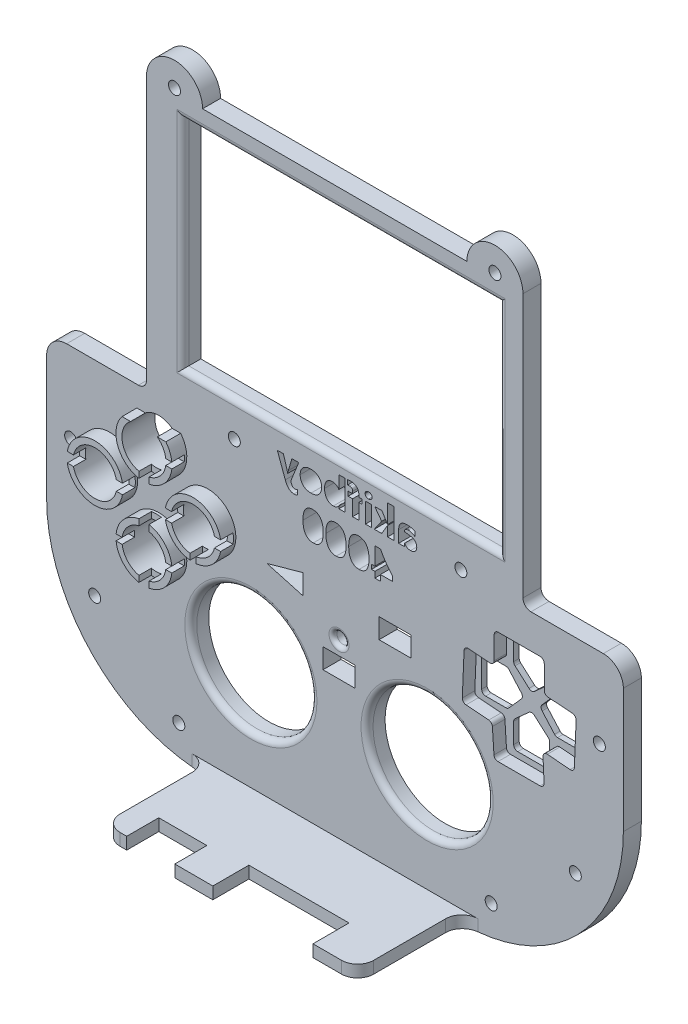
from build123d import *

# Parameters (mm, degrees)
SKETCH3_W           = 94
SKETCH3_H           = 68
SKETCH3_W_2         = 86.14
SKETCH3_H_2         = 60
SKETCH3_W_3         = 136
BOSS_EXTRUDE1_DEPTH = 4.5
FILLET1_R           = 40
FILLET3_R           = 2
FILLET4_R           = 5
SKETCH7_R           = 1.5
CUT_EXTRUDE1_DEPTH  = 5.5
SKETCH8_W           = 64
SKETCH8_H           = 3
BOSS_EXTRUDE2_DEPTH = 26
SKETCH10_W          = 12
SKETCH10_H          = 8
SKETCH10_W_2        = 25
SKETCH10_H_2        = 9
CUT_EXTRUDE2_DEPTH  = 4
SKETCH12_W          = 79
SKETCH12_H          = 54
CUT_EXTRUDE3_DEPTH  = 4.5
SKETCH13_R          = 15
CUT_EXTRUDE4_DEPTH  = 4.5
CUT_EXTRUDE5_DEPTH  = 4.5
FILLET7_R           = 1
FILLET8_R           = 1
CUT_EXTRUDE7_DEPTH  = 3.12
FILLET9_R           = 1
SKETCH16_R          = 5.5
CUT_EXTRUDE8_DEPTH  = 8.2
SKETCH17_R          = 7
SKETCH17_R_2        = 5.1
BOSS_EXTRUDE3_DEPTH = 3.7
SKETCH18_W          = 2.550563933
SKETCH18_H          = 2.5
SKETCH18_W_2        = 2.5
SKETCH18_H_2        = 2.523110448
SKETCH18_W_3        = 2.961814118
SKETCH18_H_3        = 1.5
SKETCH18_W_4        = 2.323205003
SKETCH18_W_5        = 2.376120163
SKETCH18_W_6        = 1.5
SKETCH18_H_4        = 2.429473953
SKETCH18_H_5        = 2.401401609
SKETCH18_W_7        = 2.803388964
CUT_EXTRUDE9_DEPTH  = 3.1
SKETCH19_R          = 1.5
SKETCH19_W          = 8
SKETCH19_H          = 5
CUT_EXTRUDE10_DEPTH = 4.5
SKETCH20_W          = 94
SKETCH20_H          = 4.5
CUT_EXTRUDE11_DEPTH = 0.23
SKETCH21_R          = 1.5
CUT_EXTRUDE12_DEPTH = 4.5
BOSS_EXTRUDE4_DEPTH = 4.5
SKETCH23_R          = 1.5
CUT_EXTRUDE13_DEPTH = 4.5
SKETCH24_R          = 1.5
CUT_EXTRUDE14_DEPTH = 4.5
SKETCH25_W          = 1.565789474
SKETCH25_H          = 4.973684211
CUT_EXTRUDE20_DEPTH = 4.5
SKETCH26_R          = 5.5
CUT_EXTRUDE21_DEPTH = 10
SKETCH27_W          = 13.162123603
SKETCH27_H          = 3.616908762
CUT_EXTRUDE22_DEPTH = 3.7
FILLET12_R          = 1.5
FILLET13_R          = 1
SKETCH28_W          = 29.55622263
SKETCH28_H          = 6.158319408
CUT_EXTRUDE23_DEPTH = 0.35
SKETCH29_W          = 27.097047007
SKETCH29_H          = 4.990966613
CUT_EXTRUDE24_DEPTH = 0.35
FILLET14_R          = 4


with BuildPart() as part:
    # Sketch3 → Boss-Extrude1 (new body)
    with BuildSketch(Plane.XY):
        Rectangle(SKETCH3_W, SKETCH3_H)
        Rectangle(SKETCH3_W_2, SKETCH3_H_2, mode=Mode.SUBTRACT)
        Polygon((47, -34), (-47, -34), (-71.93, -34), (-71.93, -110), (72.07, -110), (72.07, -34), align=None)
        with Locations((0.07, -72)):
            Rectangle(SKETCH3_W_3, SKETCH3_H, mode=Mode.SUBTRACT)
        Rectangle(SKETCH3_W_2, SKETCH3_H_2)
        with Locations((0.07, -72)):
            Rectangle(SKETCH3_W_3, SKETCH3_H)
    extrude(amount=BOSS_EXTRUDE1_DEPTH)

    # Fillet1
    fillet1_edges = [part.edges().sort_by_distance(p)[0] for p in [
        (72.07, -110, 2.25),
        (-71.93, -110, 2.25),
    ]]
    fillet(fillet1_edges, radius=FILLET1_R)

    # Fillet3
    fillet3_edges = [part.edges().sort_by_distance(p)[0] for p in [
        (47, -34, 2.25),
        (-47, -34, 2.25),
    ]]
    fillet(fillet3_edges, radius=FILLET3_R)

    # Fillet4
    fillet4_edges = [part.edges().sort_by_distance(p)[0] for p in [
        (72.07, -34, 2.25),
        (-71.93, -34, 2.25),
    ]]
    fillet(fillet4_edges, radius=FILLET4_R)

    # Sketch7 → Cut-Extrude1 (cut, through all)
    with BuildSketch(Plane.XY.offset(4.5)):
        with Locations((-25.07, -33.7)):
            Circle(SKETCH7_R)
        with Locations((31.5, -33.7)):
            Circle(SKETCH7_R)
    extrude(amount=-CUT_EXTRUDE1_DEPTH, mode=Mode.SUBTRACT)

    # Sketch8 → Boss-Extrude2 (add)
    with BuildSketch(Plane.XY.offset(4.5)):
        with Locations((0.07, -108.5)):
            Rectangle(SKETCH8_W, SKETCH8_H)
    extrude(amount=BOSS_EXTRUDE2_DEPTH)

    # Sketch10 → Cut-Extrude2 (cut)
    with BuildSketch(Plane.XZ.offset(110)):
        with Locations((-19.93, 26.5)):
            Rectangle(SKETCH10_W, SKETCH10_H)
        with Locations((8.07, 26)):
            Rectangle(SKETCH10_W_2, SKETCH10_H_2)
    extrude(amount=-CUT_EXTRUDE2_DEPTH, mode=Mode.SUBTRACT)

    # Sketch12 → Cut-Extrude3 (cut)
    with BuildSketch(Plane(origin=(0, 0, 0), x_dir=(-1, 0, 0), z_dir=(0, 0, -1))):
        with Locations((-1.57, 1.97)):
            Rectangle(SKETCH12_W, SKETCH12_H)
    extrude(amount=-CUT_EXTRUDE3_DEPTH, mode=Mode.SUBTRACT)

    # Sketch13 → Cut-Extrude4 (cut)
    with BuildSketch(Plane(origin=(0, 0, 0), x_dir=(-1, 0, 0), z_dir=(0, 0, -1))):
        with Locations((-23.07, -80)):
            Circle(SKETCH13_R)
        with Locations((20.93, -80)):
            Circle(SKETCH13_R)
    extrude(amount=-CUT_EXTRUDE4_DEPTH, mode=Mode.SUBTRACT)

    # Sketch14 → Cut-Extrude5 (cut)
    with BuildSketch(Plane(origin=(0, 0, 0), x_dir=(-1, 0, 0), z_dir=(0, 0, -1))):
        Polygon((-50.57, -50.5), (-46.07, -54.5), (-41.57, -50.5), (-41.57, -44), (-50.57, -44), align=None)
        Polygon((-50.57, -69), (-50.57, -62.5), (-46.07, -58.5), (-41.57, -62.5), (-41.57, -69), align=None)
        Polygon((-33.57, -52), (-33.57, -61), (-40.07, -61), (-44.07, -56.5), (-40.07, -52), align=None)
        Polygon((-58.57, -52), (-52.07, -52), (-48.07, -56.5), (-52.07, -61), (-58.57, -61), align=None)
    extrude(amount=-CUT_EXTRUDE5_DEPTH, mode=Mode.SUBTRACT)

    # Fillet7
    fillet7_edges = [part.edges().sort_by_distance(p)[0] for p in [
        (58.57, -61, 2.25),
        (58.57, -52, 2.25),
        (52.07, -52, 2.25),
        (48.07, -56.5, 2.25),
        (52.07, -61, 2.25),
        (50.57, -50.5, 2.25),
        (50.57, -44, 2.25),
        (41.57, -44, 2.25),
        (41.57, -50.5, 2.25),
        (46.07, -54.5, 2.25),
    ]]
    fillet(fillet7_edges, radius=FILLET7_R)

    # Fillet8
    fillet8_edges = [part.edges().sort_by_distance(p)[0] for p in [
        (40.07, -52, 2.25),
        (33.57, -52, 2.25),
        (33.57, -61, 2.25),
        (40.07, -61, 2.25),
        (44.07, -56.5, 2.25),
        (41.57, -69, 2.25),
        (50.57, -69, 2.25),
        (50.57, -62.5, 2.25),
        (46.07, -58.5, 2.25),
        (41.57, -62.5, 2.25),
    ]]
    fillet(fillet8_edges, radius=FILLET8_R)

    # Sketch15 → Cut-Extrude7 (cut)
    with BuildSketch(Plane.XY.offset(4.5)):
        Polygon((39.82, -42.5), (52.32, -42.5), (52.32, -50.25), (60.319152007, -50.841010066), (59.796347383, -63.330072293), (51.96198572, -62.643790261), (52.32, -70.5), (39.82, -70.5), (39.32, -62.75), (31.820847993, -62.158989934), (32.343652617, -49.669927707), (39.82, -50.25), align=None)
    extrude(amount=-CUT_EXTRUDE7_DEPTH, mode=Mode.SUBTRACT)

    # Fillet9
    fillet9_edges = [part.edges().sort_by_distance(p)[0] for p in [
        (39.82, -50.25, 2.94),
        (39.82, -42.5, 2.94),
        (52.32, -42.5, 2.94),
        (52.32, -50.25, 2.94),
        (60.319152007, -50.841010066, 2.94),
        (59.796347383, -63.330072293, 2.94),
        (51.96198572, -62.643790261, 2.94),
        (52.32, -70.5, 2.94),
        (39.82, -70.5, 2.94),
        (39.32, -62.75, 2.94),
        (31.820847993, -62.158989934, 2.94),
        (32.343652617, -49.669927707, 2.94),
    ]]
    fillet(fillet9_edges, radius=FILLET9_R)

    # Sketch16 → Cut-Extrude8 (cut)
    with BuildSketch(Plane(origin=(0, 0, 0), x_dir=(-1, 0, 0), z_dir=(0, 0, -1))):
        with Locations((43.93, -43.5)):
            Circle(SKETCH16_R)
        with Locations((31.68, -54.75)):
            Circle(SKETCH16_R)
        with Locations((56.18, -54.75)):
            Circle(SKETCH16_R)
        with Locations((43.93, -66)):
            Circle(SKETCH16_R)
    extrude(amount=-CUT_EXTRUDE8_DEPTH, mode=Mode.SUBTRACT)

    # Sketch17 → Boss-Extrude3 (add)
    with BuildSketch(Plane.XY.offset(4.5)):
        with Locations((-43.93, -43.5)):
            Circle(SKETCH17_R)
        with Locations((-43.93, -43.5)):
            Circle(SKETCH17_R_2, mode=Mode.SUBTRACT)
        with Locations((-31.68, -54.75)):
            Circle(SKETCH17_R)
        with Locations((-31.68, -54.75)):
            Circle(SKETCH17_R_2, mode=Mode.SUBTRACT)
        with Locations((-43.93, -66)):
            Circle(SKETCH17_R)
        with Locations((-43.93, -66)):
            Circle(SKETCH17_R_2, mode=Mode.SUBTRACT)
        with Locations((-56.18, -54.75)):
            Circle(SKETCH17_R)
        with Locations((-56.18, -54.75)):
            Circle(SKETCH17_R_2, mode=Mode.SUBTRACT)
    extrude(amount=BOSS_EXTRUDE3_DEPTH)

    # Sketch18 → Cut-Extrude9 (cut)
    with BuildSketch(Plane.XY.offset(8.2)):
        with Locations((-62.358387201, -54.75)):
            Rectangle(SKETCH18_W, SKETCH18_H)
        with Locations((-50.0016128, -54.75)):
            Rectangle(SKETCH18_W, SKETCH18_H)
        with Locations((-43.93, -49.575016155)):
            Rectangle(SKETCH18_W_2, SKETCH18_H_2)
        with Locations((-43.93, -37.424983845)):
            Rectangle(SKETCH18_W_2, SKETCH18_H_2)
        with Locations((-37.86326354, -43.5)):
            Rectangle(SKETCH18_W_3, SKETCH18_H_3)
        with Locations((-37.676163082, -54.75)):
            Rectangle(SKETCH18_W_4, SKETCH18_H)
        with Locations((-25.845860503, -54.75)):
            Rectangle(SKETCH18_W_5, SKETCH18_H)
        with Locations((-31.68, -60.701386037)):
            Rectangle(SKETCH18_W_6, SKETCH18_H_4)
        with Locations((-43.93, -60.086956195)):
            Rectangle(SKETCH18_W_2, SKETCH18_H_5)
        with Locations((-43.93, -71.913043805)):
            Rectangle(SKETCH18_W_2, SKETCH18_H_5)
        with Locations((-38.240309623, -66)):
            Rectangle(SKETCH18_W_7, SKETCH18_H_3)
        with Locations((-49.619690377, -66)):
            Rectangle(SKETCH18_W_7, SKETCH18_H_3)
    extrude(amount=-CUT_EXTRUDE9_DEPTH, mode=Mode.SUBTRACT)

    # Sketch19 → Cut-Extrude10 (cut)
    with BuildSketch(Plane(origin=(0, 0, 0), x_dir=(-1, 0, 0), z_dir=(0, 0, -1))):
        with Locations((-1.07, -64)):
            Circle(SKETCH19_R)
        Polygon((7.93, -54), (7.93, -59), (16.93, -56.5), align=None)
        with Locations((-15.07, -56.5)):
            Rectangle(SKETCH19_W, SKETCH19_H)
        with Locations((-1.07, -70)):
            Rectangle(SKETCH19_W, SKETCH19_H)
    extrude(amount=-CUT_EXTRUDE10_DEPTH, mode=Mode.SUBTRACT)

    # Sketch20 → Cut-Extrude11 (cut)
    with BuildSketch(Plane(origin=(0, 34, 0), x_dir=(1, 0, 0), z_dir=(0, 1, 0))):
        with Locations((0, -2.25)):
            Rectangle(SKETCH20_W, SKETCH20_H)
    extrude(amount=-CUT_EXTRUDE11_DEPTH, mode=Mode.SUBTRACT)

    # Sketch21 → Cut-Extrude12 (cut)
    with BuildSketch(Plane(origin=(0, 0, 0), x_dir=(-1, 0, 0), z_dir=(0, 0, -1))):
        with Locations((-39.07, -102)):
            Circle(SKETCH21_R)
        with Locations((38.93, -102)):
            Circle(SKETCH21_R)
    extrude(amount=-CUT_EXTRUDE12_DEPTH, mode=Mode.SUBTRACT)

    # Sketch22 → Boss-Extrude4 (add)
    with BuildSketch(Plane(origin=(0, 0, 0), x_dir=(-1, 0, 0), z_dir=(0, 0, -1))):
        with BuildLine():
            Line((-47, 33.77), (-33, 33.77))
            ThreePointArc((-33, 33.77), (-40, 40.77), (-47, 33.77))
        make_face()
        with BuildLine():
            Line((47, 33.77), (33, 33.77))
            ThreePointArc((33, 33.77), (40, 40.77), (47, 33.77))
        make_face()
    extrude(amount=-BOSS_EXTRUDE4_DEPTH)

    # Sketch23 → Cut-Extrude13 (cut)
    with BuildSketch(Plane(origin=(0, 0, 0), x_dir=(-1, 0, 0), z_dir=(0, 0, -1))):
        with Locations((-40, 34.77)):
            Circle(SKETCH23_R)
        with Locations((40, 34.77)):
            Circle(SKETCH23_R)
    extrude(amount=-CUT_EXTRUDE13_DEPTH, mode=Mode.SUBTRACT)

    # Sketch24 → Cut-Extrude14 (cut)
    with BuildSketch(Plane(origin=(0, 0, 0), x_dir=(-1, 0, 0), z_dir=(0, 0, -1))):
        with Locations((65.93, -54)):
            Circle(SKETCH24_R)
        with Locations((59.93, -85)):
            Circle(SKETCH24_R)
        with Locations((-66.07, -54)):
            Circle(SKETCH24_R)
        with Locations((-60.07, -85)):
            Circle(SKETCH24_R)
    extrude(amount=-CUT_EXTRUDE14_DEPTH, mode=Mode.SUBTRACT)

    # Sketch25 → Cut-Extrude20 (cut)
    with BuildSketch(Plane(origin=(0, 0, 0), x_dir=(-1, 0, 0), z_dir=(0, 0, -1))):
        with BuildLine():
            Line((14.331052632, -30.726315789), (12.339276316, -36.141817434))
            add(Edge.make_bspline(
                [(12.339276316, -36.141817434), (12.309435587, -36.220844542), (12.25099053, -36.375624399), (12.15089745, -36.596311688), (12.047921736, -36.803734021), (11.936884142, -36.994401064), (11.822187613, -37.171037104), (11.700673172, -37.331398984), (11.57431277, -37.477166889), (11.44167923, -37.607999313), (11.301372746, -37.721126414), (11.15745927, -37.821823684), (11.006627122, -37.905247886), (10.850969781, -37.97521784), (10.689104709, -38.027906022), (10.522248726, -38.067554511), (10.349131502, -38.090985435), (10.231479495, -38.093476083), (10.171924342, -38.094736842)],
                knots=[0, 0, 0, 0, 0.000253355, 0.000496212, 0.000726624, 0.000947794, 0.001157751, 0.001358082, 0.001550868, 0.001736088, 0.001916125, 0.002090974, 0.002262347, 0.002432434, 0.002602186, 0.002772188, 0.002946413, 0.003125012, 0.003125012, 0.003125012, 0.003125012], degree=3))
            add(Edge.make_bspline(
                [(10.171924342, -38.094736842), (10.0839903, -38.092780835), (9.915538502, -38.089033788), (9.675343221, -38.053815015), (9.457872968, -37.999033788), (9.327881454, -37.939300484), (9.265263158, -37.910526316)],
                knots=[0, 0, 0, 0, 0.000263615, 0.000504997, 0.000727022, 0.000933378, 0.000933378, 0.000933378, 0.000933378], degree=3))
            Line((9.265263158, -37.910526316), (9.265263158, -36.713157895))
            add(Edge.make_bspline(
                [(9.265263158, -36.713157895), (9.315373417, -36.741592816), (9.414801427, -36.798012951), (9.576382338, -36.854580595), (9.743814417, -36.891076839), (9.857996079, -36.895254891), (9.915756579, -36.897368421)],
                knots=[0, 0, 0, 0, 0.000172529, 0.00034233, 0.000511398, 0.000684478, 0.000684478, 0.000684478, 0.000684478], degree=3))
            add(Edge.make_bspline(
                [(9.915756579, -36.897368421), (9.962407983, -36.895802705), (10.052646598, -36.892774113), (10.182564561, -36.866817624), (10.301031255, -36.821539426), (10.408257758, -36.758569261), (10.5067581, -36.680804272), (10.590591291, -36.581493919), (10.66415487, -36.465986333), (10.703052198, -36.380301273), (10.723116776, -36.336101974)],
                knots=[0, 0, 0, 0, 0.000139864, 0.000270541, 0.000395357, 0.000518528, 0.00064237, 0.000769903, 0.00090644, 0.001051907, 0.001051907, 0.001051907, 0.001051907], degree=3))
            Line((10.723116776, -36.336101974), (10.979284539, -35.715830592))
            Line((10.979284539, -35.715830592), (8.988947368, -30.726315789))
            Line((8.988947368, -30.726315789), (10.688577303, -30.726315789))
            Line((10.688577303, -30.726315789), (11.589481908, -33.772985197))
            add(Edge.make_bspline(
                [(11.589481908, -33.772985197), (11.603370114, -33.822277684), (11.632189823, -33.924565559), (11.667828036, -34.085940109), (11.69776615, -34.260365129), (11.713668278, -34.381202677), (11.721883224, -34.443626645)],
                knots=[0, 0, 0, 0, 0.000153611, 0.000318762, 0.000495502, 0.000684376, 0.000684376, 0.000684376, 0.000684376], degree=3))
            Line((11.721883224, -34.443626645), (11.740592105, -34.443626645))
            add(Edge.make_bspline(
                [(11.740592105, -34.443626645), (11.74880851, -34.394138093), (11.765872062, -34.291361938), (11.80107938, -34.131962601), (11.84617424, -33.961476505), (11.879965, -33.843919752), (11.897458882, -33.783059211)],
                knots=[0, 0, 0, 0, 0.000150478, 0.000312508, 0.000489482, 0.000679455, 0.000679455, 0.000679455, 0.000679455], degree=3))
            Line((11.897458882, -33.783059211), (12.809876645, -30.726315789))
            Line((12.809876645, -30.726315789), (14.331052632, -30.726315789))
        make_face()
        with BuildLine():
            add(Edge.make_bspline(
                [(5.925008224, -35.792105263), (5.82463653, -35.790573816), (5.629066873, -35.787589862), (5.344796963, -35.752788216), (5.076486328, -35.701148771), (4.825322649, -35.623898458), (4.589186289, -35.527694534), (4.368828149, -35.409711049), (4.166897637, -35.267539879), (3.982027012, -35.106019501), (3.816426271, -34.926075388), (3.67191748, -34.729783848), (3.549674956, -34.517403062), (3.451318538, -34.289609069), (3.372102271, -34.047067807), (3.318976159, -33.788760166), (3.284835927, -33.515330455), (3.280594694, -33.327916731), (3.278421053, -33.231866776)],
                knots=[0, 0, 0, 0, 0.00030095, 0.000586387, 0.000857902, 0.001119672, 0.001373296, 0.001621848, 0.001867786, 0.002112559, 0.002357002, 0.00259994, 0.00284235, 0.003090472, 0.003343061, 0.003606409, 0.003880414, 0.004168473, 0.004168473, 0.004168473, 0.004168473], degree=3))
            add(Edge.make_bspline(
                [(3.278421053, -33.231866776), (3.280535444, -33.132944833), (3.284664906, -32.939747691), (3.319610134, -32.658354216), (3.377192299, -32.393984975), (3.455660946, -32.145326326), (3.560603222, -31.914473314), (3.685355683, -31.697836538), (3.836543839, -31.500372902), (4.008136476, -31.319659663), (4.200049693, -31.159088566), (4.407539139, -31.016906055), (4.632764216, -30.898187395), (4.873986665, -30.802775564), (5.130202626, -30.724907008), (5.403855379, -30.673599012), (5.692887999, -30.638832469), (5.891319405, -30.635772893), (5.992648026, -30.634210526)],
                knots=[0, 0, 0, 0, 0.000296687, 0.000579438, 0.000849019, 0.001107529, 0.001360033, 0.001608342, 0.001855879, 0.002104256, 0.002354489, 0.002605165, 0.002857525, 0.003116483, 0.003382386, 0.003659547, 0.003950703, 0.00425453, 0.00425453, 0.00425453, 0.00425453], degree=3))
            add(Edge.make_bspline(
                [(5.992648026, -30.634210526), (6.092543008, -30.635730023), (6.287162068, -30.638690363), (6.570431535, -30.673704113), (6.837886429, -30.724924538), (7.088000332, -30.802504917), (7.322483782, -30.898225391), (7.54047563, -31.017069173), (7.740719771, -31.158772916), (7.924271956, -31.320260037), (8.087337991, -31.50003842), (8.231702988, -31.693426843), (8.350607496, -31.902625863), (8.451513235, -32.123559396), (8.527159583, -32.359975241), (8.58200341, -32.609484453), (8.613515903, -32.873195716), (8.618153114, -33.053330084), (8.620526316, -33.145518092)],
                knots=[0, 0, 0, 0, 0.000299512, 0.000583519, 0.000855034, 0.001115428, 0.001367722, 0.001613744, 0.001858504, 0.002102196, 0.002345667, 0.002585435, 0.002824632, 0.003066176, 0.003312846, 0.003567753, 0.003831584, 0.00410814, 0.00410814, 0.00410814, 0.00410814], degree=3))
            add(Edge.make_bspline(
                [(8.620526316, -33.145518092), (8.618292567, -33.244909846), (8.613930846, -33.438986728), (8.580607932, -33.722253114), (8.524791517, -33.989736049), (8.44613107, -34.241353546), (8.342494274, -34.476090314), (8.219390227, -34.696233489), (8.070917448, -34.898601558), (7.902455416, -35.084652276), (7.714257952, -35.251920581), (7.506853044, -35.39596555), (7.284410984, -35.519404622), (7.044052431, -35.618506347), (6.788148034, -35.698476879), (6.514422212, -35.751595958), (6.225214977, -35.78571813), (6.026809855, -35.789939354), (5.925008224, -35.792105263)],
                knots=[0, 0, 0, 0, 0.000298125, 0.000582133, 0.000854227, 0.00111685, 0.0013714, 0.001622735, 0.001872019, 0.002122654, 0.002374471, 0.002625597, 0.002878743, 0.003136129, 0.003404246, 0.003681688, 0.003971414, 0.00427673, 0.00427673, 0.00427673, 0.00427673], degree=3))
        make_face()
        with BuildLine():
            Line((-1.031817434, -35.069654605), (-1.050526316, -35.069654605))
            Line((-1.050526316, -35.069654605), (-1.050526316, -35.7))
            Line((-1.050526316, -35.7), (-2.616315789, -35.7))
            Line((-2.616315789, -35.7), (-2.616315789, -28.331578947))
            Line((-2.616315789, -28.331578947), (-1.050526316, -28.331578947))
            Line((-1.050526316, -28.331578947), (-1.050526316, -31.526480263))
            Line((-1.050526316, -31.526480263), (-1.031817434, -31.526480263))
            add(Edge.make_bspline(
                [(-1.031817434, -31.526480263), (-0.984047056, -31.455673996), (-0.890819126, -31.317489583), (-0.726260308, -31.135353995), (-0.548751979, -30.978736508), (-0.353978558, -30.853553028), (-0.145737277, -30.753082099), (0.07871865, -30.685545028), (0.317385729, -30.642089955), (0.481485287, -30.6368814), (0.565633224, -30.634210526)],
                knots=[0, 0, 0, 0, 0.000255966, 0.000499538, 0.000734159, 0.000964084, 0.001191965, 0.001425484, 0.001665165, 0.001917426, 0.001917426, 0.001917426, 0.001917426], degree=3))
            add(Edge.make_bspline(
                [(0.565633224, -30.634210526), (0.642476456, -30.636101007), (0.792468479, -30.639791079), (1.010795915, -30.669781204), (1.214887132, -30.722534622), (1.406661306, -30.791948296), (1.583387576, -30.885665345), (1.747769986, -30.997937017), (1.895997208, -31.133618487), (2.032031108, -31.286639873), (2.152523244, -31.457660552), (2.255862032, -31.645108124), (2.346257068, -31.845734746), (2.417540065, -32.063052753), (2.473101981, -32.29464371), (2.513789647, -32.540824763), (2.536133034, -32.802106322), (2.53973032, -32.981415009), (2.541578947, -33.073560855)],
                knots=[0, 0, 0, 0, 0.000230483, 0.000449886, 0.000659315, 0.000861948, 0.001060216, 0.00125782, 0.001457534, 0.001661426, 0.001871053, 0.002083662, 0.0023027, 0.002530249, 0.002768652, 0.003016603, 0.003278104, 0.003554555, 0.003554555, 0.003554555, 0.003554555], degree=3))
            add(Edge.make_bspline(
                [(2.541578947, -33.073560855), (2.539451692, -33.173395534), (2.535291301, -33.368647679), (2.508434326, -33.654552929), (2.460741034, -33.924758354), (2.396304198, -34.180715334), (2.311960751, -34.420866834), (2.20713095, -34.645235231), (2.086397716, -34.855880304), (1.945714949, -35.048630452), (1.790791338, -35.224053632), (1.620140983, -35.375463939), (1.437790187, -35.504457699), (1.243352727, -35.611537618), (1.034547918, -35.690935649), (0.814533175, -35.751059987), (0.581125601, -35.785735421), (0.421351954, -35.789950716), (0.3396875, -35.792105263)],
                knots=[0, 0, 0, 0, 0.000299512, 0.000585771, 0.000860467, 0.001121905, 0.0013768, 0.001622759, 0.001863922, 0.002104, 0.002337413, 0.002564729, 0.002786736, 0.003006341, 0.003228697, 0.003455265, 0.003689528, 0.003934453, 0.003934453, 0.003934453, 0.003934453], degree=3))
            add(Edge.make_bspline(
                [(0.3396875, -35.792105263), (0.266656057, -35.789841168), (0.124130559, -35.785422642), (-0.083563533, -35.752479588), (-0.277236408, -35.69448279), (-0.457379949, -35.615075116), (-0.623576742, -35.513103147), (-0.775570619, -35.388266199), (-0.914022837, -35.240080208), (-0.991949532, -35.127335615), (-1.031817434, -35.069654605)],
                knots=[0, 0, 0, 0, 0.000219053, 0.000427495, 0.000628749, 0.00082397, 0.001016493, 0.001211819, 0.001412419, 0.001622553, 0.001622553, 0.001622553, 0.001622553], degree=3))
        make_face()
        with BuildLine():
            add(Edge.make_bspline(
                [(-3.168947368, -29.528947368), (-3.216723741, -29.514742492), (-3.310967111, -29.486722042), (-3.453074273, -29.458750598), (-3.592523048, -29.440176214), (-3.684582905, -29.437947034), (-3.730213816, -29.436842105)],
                knots=[0, 0, 0, 0, 0.000149449, 0.000294803, 0.000434036, 0.000570876, 0.000570876, 0.000570876, 0.000570876], degree=3))
            add(Edge.make_bspline(
                [(-3.730213816, -29.436842105), (-3.787576416, -29.43839805), (-3.895564895, -29.441327208), (-4.045811982, -29.480214935), (-4.174893721, -29.540012116), (-4.280245395, -29.62818461), (-4.363111026, -29.740308287), (-4.417837897, -29.878144841), (-4.453231939, -30.038063651), (-4.456617453, -30.152836279), (-4.458421053, -30.213980263)],
                knots=[0, 0, 0, 0, 0.000171645, 0.000323131, 0.000462164, 0.000595018, 0.000730878, 0.00087601, 0.001036635, 0.001219768, 0.001219768, 0.001219768, 0.001219768], degree=3))
            Line((-4.458421053, -30.213980263), (-4.458421053, -30.726315789))
            Line((-4.458421053, -30.726315789), (-3.353157895, -30.726315789))
            Line((-3.353157895, -30.726315789), (-3.353157895, -31.831578947))
            Line((-3.353157895, -31.831578947), (-4.458421053, -31.831578947))
            Line((-4.458421053, -31.831578947), (-4.458421053, -35.7))
            Line((-4.458421053, -35.7), (-6.024210526, -35.7))
            Line((-6.024210526, -35.7), (-6.024210526, -31.831578947))
            Line((-6.024210526, -31.831578947), (-6.853157895, -31.831578947))
            Line((-6.853157895, -31.831578947), (-6.853157895, -30.726315789))
            Line((-6.853157895, -30.726315789), (-6.024210526, -30.726315789))
            Line((-6.024210526, -30.726315789), (-6.024210526, -30.114679276))
            add(Edge.make_bspline(
                [(-6.024210526, -30.114679276), (-6.022628178, -30.045993583), (-6.019529149, -29.911472696), (-5.993069916, -29.715321919), (-5.9502718, -29.528908808), (-5.887942871, -29.353670913), (-5.809892213, -29.187166763), (-5.713083373, -29.032218807), (-5.599946187, -28.88635789), (-5.46884875, -28.753505353), (-5.323784467, -28.632205669), (-5.164373145, -28.526833445), (-4.992828763, -28.437164954), (-4.808038394, -28.365636678), (-4.611931842, -28.307326522), (-4.402679482, -28.267672879), (-4.18117559, -28.244859426), (-4.029610108, -28.241300013), (-3.951842105, -28.239473684)],
                knots=[0, 0, 0, 0, 0.000205979, 0.000403409, 0.000592612, 0.000778774, 0.000960312, 0.001143219, 0.001325735, 0.00151299, 0.001702044, 0.001892039, 0.002085147, 0.002281573, 0.002485587, 0.002698118, 0.002919508, 0.003152809, 0.003152809, 0.003152809, 0.003152809], degree=3))
            add(Edge.make_bspline(
                [(-3.951842105, -28.239473684), (-3.876483139, -28.240447199), (-3.732266207, -28.242310245), (-3.52609977, -28.259880383), (-3.339468798, -28.2867945), (-3.223902519, -28.317145946), (-3.168947368, -28.331578947)],
                knots=[0, 0, 0, 0, 0.000226019, 0.00043254, 0.000620408, 0.000790744, 0.000790744, 0.000790744, 0.000790744], degree=3))
            Line((-3.168947368, -28.331578947), (-3.168947368, -29.528947368))
        make_face()
        with BuildLine():
            add(Edge.make_bspline(
                [(-8.465, -29.897368421), (-8.526206527, -29.894819394), (-8.644979388, -29.889872939), (-8.813885792, -29.845529357), (-8.966665194, -29.774049785), (-9.097627706, -29.673542334), (-9.20491091, -29.552755134), (-9.282973123, -29.416154608), (-9.331220259, -29.265865907), (-9.337032252, -29.160884217), (-9.34, -29.107277961)],
                knots=[0, 0, 0, 0, 0.000183337, 0.00035577, 0.000519921, 0.00068629, 0.000847397, 0.001001446, 0.001155294, 0.001315821, 0.001315821, 0.001315821, 0.001315821], degree=3))
            add(Edge.make_bspline(
                [(-9.34, -29.107277961), (-9.337158955, -29.052211587), (-9.331666079, -28.945746255), (-9.283126312, -28.794517668), (-9.205975579, -28.659307707), (-9.097196562, -28.543610176), (-8.965635171, -28.449171338), (-8.813492979, -28.380703439), (-8.644857488, -28.337606123), (-8.526193889, -28.333629606), (-8.465, -28.331578947)],
                knots=[0, 0, 0, 0, 0.000164824, 0.000318672, 0.000471472, 0.000628306, 0.000791254, 0.000954189, 0.001126267, 0.001309497, 0.001309497, 0.001309497, 0.001309497], degree=3))
            add(Edge.make_bspline(
                [(-8.465, -28.331578947), (-8.402818847, -28.333522316), (-8.283141762, -28.337262623), (-8.113415067, -28.381198656), (-7.960655845, -28.447877364), (-7.831132463, -28.544659397), (-7.722627768, -28.659221911), (-7.645055151, -28.794280376), (-7.598793144, -28.946026154), (-7.59300023, -29.052258683), (-7.59, -29.107277961)],
                knots=[0, 0, 0, 0, 0.000186101, 0.00035818, 0.000522425, 0.000683043, 0.000839877, 0.000992677, 0.001146099, 0.001310924, 0.001310924, 0.001310924, 0.001310924], degree=3))
            add(Edge.make_bspline(
                [(-7.59, -29.107277961), (-7.593046483, -29.162763357), (-7.598954775, -29.270370682), (-7.644997043, -29.424487544), (-7.722550459, -29.562312535), (-7.830552605, -29.679926971), (-7.960620944, -29.777960276), (-8.113048607, -29.846729086), (-8.283248501, -29.889793913), (-8.402844189, -29.894778073), (-8.465, -29.897368421)],
                knots=[0, 0, 0, 0, 0.000166257, 0.000322436, 0.000477737, 0.000636695, 0.000798169, 0.000963012, 0.00113509, 0.001321297, 0.001321297, 0.001321297, 0.001321297], degree=3))
        make_face()
        with Locations((-8.465, -33.213157895)):
            Rectangle(SKETCH25_W, SKETCH25_H)
        Polygon((-9.892631579, -35.7), (-11.733297697, -35.7), (-13.191151316, -33.231866776), (-13.208421053, -33.231866776), (-13.208421053, -35.7), (-14.774210526, -35.7), (-14.774210526, -28.331578947), (-13.208421053, -28.331578947), (-13.208421053, -33.023190789), (-13.189712171, -33.023190789), (-11.806694079, -30.726315789), (-9.984736842, -30.726315789), (-11.727541118, -33.062047697), align=None)
        with BuildLine():
            Line((-15.971578947, -35.7), (-17.445263158, -35.7))
            Line((-17.445263158, -35.7), (-17.445263158, -34.940131579))
            Line((-17.445263158, -34.940131579), (-17.463972039, -34.940131579))
            add(Edge.make_bspline(
                [(-17.463972039, -34.940131579), (-17.506429315, -35.008007619), (-17.589001681, -35.140015273), (-17.738071993, -35.313801217), (-17.899703585, -35.463091399), (-18.079134065, -35.583543004), (-18.272864426, -35.677764588), (-18.481805942, -35.743967207), (-18.705251629, -35.785632188), (-18.859751734, -35.789908936), (-18.939095395, -35.792105263)],
                knots=[0, 0, 0, 0, 0.000239889, 0.000466544, 0.000684554, 0.000898101, 0.001112437, 0.00132862, 0.001553882, 0.001791694, 0.001791694, 0.001791694, 0.001791694], degree=3))
            add(Edge.make_bspline(
                [(-18.939095395, -35.792105263), (-18.997692416, -35.791340265), (-19.111902248, -35.789849228), (-19.277824322, -35.768425257), (-19.434499016, -35.737428602), (-19.581736436, -35.69304674), (-19.718848203, -35.635004091), (-19.847465983, -35.565837949), (-19.964985041, -35.481773238), (-20.0738328, -35.387016728), (-20.169121519, -35.279921052), (-20.255896923, -35.166342281), (-20.326157735, -35.04137984), (-20.383216526, -34.908369599), (-20.430621053, -34.768204913), (-20.460914461, -34.618287912), (-20.482411936, -34.460561477), (-20.48395237, -34.352079044), (-20.484736842, -34.296833882)],
                knots=[0, 0, 0, 0, 0.00017567, 0.000342394, 0.000501013, 0.000654436, 0.000802779, 0.000947039, 0.001091585, 0.001235363, 0.001379025, 0.001520925, 0.001663371, 0.001807746, 0.001954743, 0.002106318, 0.002265901, 0.002431503, 0.002431503, 0.002431503, 0.002431503], degree=3))
            add(Edge.make_bspline(
                [(-20.484736842, -34.296833882), (-20.483319055, -34.238726624), (-20.480544995, -34.125033168), (-20.459906585, -33.958930819), (-20.427472437, -33.802233787), (-20.381301825, -33.654878662), (-20.320265388, -33.517701957), (-20.247010878, -33.389048316), (-20.160081438, -33.270296868), (-20.059624364, -33.161273823), (-19.945650305, -33.062012868), (-19.818231693, -32.972510466), (-19.677265898, -32.892994042), (-19.523249891, -32.823488892), (-19.357047866, -32.76023072), (-19.175942108, -32.711246302), (-18.982349197, -32.66927999), (-18.848085685, -32.649212546), (-18.779350329, -32.638939145)],
                knots=[0, 0, 0, 0, 0.000174285, 0.000341009, 0.00050133, 0.000653804, 0.000803288, 0.000950911, 0.001097139, 0.001243804, 0.001394757, 0.001549677, 0.001710153, 0.00187952, 0.002056213, 0.002243025, 0.002441742, 0.002650184, 0.002650184, 0.002650184, 0.002650184], degree=3))
            Line((-18.779350329, -32.638939145), (-17.435189145, -32.460485197))
            add(Edge.make_bspline(
                [(-17.435189145, -32.460485197), (-17.437735933, -32.396912726), (-17.442564438, -32.276384479), (-17.484206213, -32.107742162), (-17.554145252, -31.963711562), (-17.653081214, -31.844471716), (-17.782887905, -31.753443097), (-17.940080997, -31.691082534), (-18.123780011, -31.653832633), (-18.254829797, -31.649613852), (-18.324580592, -31.647368421)],
                knots=[0, 0, 0, 0, 0.000190511, 0.000361194, 0.000516948, 0.000667123, 0.00082087, 0.000987369, 0.001171113, 0.00138019, 0.00138019, 0.00138019, 0.00138019], degree=3))
            add(Edge.make_bspline(
                [(-18.324580592, -31.647368421), (-18.398528969, -31.649041406), (-18.54639614, -31.652386707), (-18.766364304, -31.679027021), (-18.983771826, -31.722544784), (-19.198049328, -31.782736081), (-19.409481564, -31.861413), (-19.618201099, -31.956587853), (-19.824869713, -32.06866425), (-19.957177758, -32.155835442), (-20.024210526, -32.2)],
                knots=[0, 0, 0, 0, 0.000221796, 0.000443504, 0.000663651, 0.00088644, 0.001110466, 0.001339742, 0.001574164, 0.001814897, 0.001814897, 0.001814897, 0.001814897], degree=3))
            Line((-20.024210526, -32.2), (-20.024210526, -31.050123355))
            add(Edge.make_bspline(
                [(-20.024210526, -31.050123355), (-19.965579976, -31.022841658), (-19.840736705, -30.964750163), (-19.633281261, -30.891489546), (-19.397553801, -30.820983094), (-19.138262597, -30.759109378), (-18.871385373, -30.702694465), (-18.608824067, -30.665029261), (-18.359209953, -30.637881145), (-18.196564885, -30.635412805), (-18.11734375, -30.634210526)],
                knots=[0, 0, 0, 0, 0.000193906, 0.000412888, 0.000659217, 0.000931824, 0.001212372, 0.001477163, 0.001727334, 0.001964902, 0.001964902, 0.001964902, 0.001964902], degree=3))
            add(Edge.make_bspline(
                [(-18.11734375, -30.634210526), (-18.030456045, -30.635869314), (-17.862553846, -30.639074763), (-17.618549601, -30.663684137), (-17.39176019, -30.704731259), (-17.181220714, -30.762444677), (-16.987035884, -30.835668832), (-16.808965163, -30.92562388), (-16.649953651, -31.035347723), (-16.504978682, -31.158226015), (-16.378233729, -31.299639944), (-16.269862979, -31.458545007), (-16.177118699, -31.632715496), (-16.10098962, -31.823312494), (-16.042209613, -32.030249251), (-16.000810516, -32.253299763), (-15.976526309, -32.493045638), (-15.973263483, -32.65854997), (-15.971578947, -32.743996711)],
                knots=[0, 0, 0, 0, 0.000260628, 0.000503639, 0.000734823, 0.000951293, 0.001157634, 0.001356517, 0.001548118, 0.001735903, 0.001925455, 0.002115869, 0.002311592, 0.0025163, 0.00273039, 0.002955913, 0.003196061, 0.003452374, 0.003452374, 0.003452374, 0.003452374], degree=3))
            Line((-15.971578947, -32.743996711), (-15.971578947, -35.7))
        make_face()
        with BuildLine():
            Line((-10.030789474, -39.2), (-10.030789474, -43.621052632))
            Line((-10.030789474, -43.621052632), (-9.194646382, -43.621052632))
            Line((-9.194646382, -43.621052632), (-9.194646382, -44.726315789))
            Line((-9.194646382, -44.726315789), (-10.030789474, -44.726315789))
            Line((-10.030789474, -44.726315789), (-10.030789474, -46.2))
            Line((-10.030789474, -46.2), (-11.412368421, -46.2))
            Line((-11.412368421, -46.2), (-11.412368421, -44.726315789))
            Line((-11.412368421, -44.726315789), (-14.451842105, -44.726315789))
            Line((-14.451842105, -44.726315789), (-14.451842105, -43.567804276))
            add(Edge.make_bspline(
                [(-14.451842105, -43.567804276), (-14.384021802, -43.490246188), (-14.246087977, -43.332507528), (-14.039155938, -43.089010546), (-13.827071485, -42.83604787), (-13.541139419, -42.48205756), (-13.185859417, -42.02663151), (-12.777430748, -41.463756242), (-12.387900152, -40.892587635), (-12.086237205, -40.409651083), (-11.86218459, -40.025398904), (-11.706651302, -39.745722303), (-11.564829776, -39.471774551), (-11.478982134, -39.28949367), (-11.436833882, -39.2)],
                knots=[0, 0, 0, 0, 0.000309081, 0.000628614, 0.00095863, 0.001299367, 0.001993711, 0.002691197, 0.003385339, 0.004067386, 0.00439888, 0.004719681, 0.005027348, 0.005324095, 0.005324095, 0.005324095, 0.005324095], degree=3))
            Line((-11.436833882, -39.2), (-10.030789474, -39.2))
        make_face()
        with BuildLine():
            add(Edge.make_bspline(
                [(-6.063067434, -46.292105263), (-6.163979328, -46.29007478), (-6.360013695, -46.286130304), (-6.64391188, -46.242488701), (-6.908969292, -46.176289932), (-7.154548388, -46.080421532), (-7.380900147, -45.957823819), (-7.587131465, -45.806271858), (-7.774068351, -45.628030696), (-7.940520567, -45.421723128), (-8.085588273, -45.188013764), (-8.212951875, -44.928220451), (-8.320018334, -44.641270167), (-8.407908895, -44.326895572), (-8.474032039, -43.985495505), (-8.522930205, -43.617435791), (-8.551355249, -43.22237793), (-8.555147727, -42.949977772), (-8.557105263, -42.809375)],
                knots=[0, 0, 0, 0, 0.000302498, 0.000587641, 0.000859552, 0.001120656, 0.001376326, 0.001629632, 0.001886148, 0.002149117, 0.002422638, 0.002709693, 0.003015747, 0.003340146, 0.003687865, 0.004058095, 0.00445347, 0.004875259, 0.004875259, 0.004875259, 0.004875259], degree=3))
            add(Edge.make_bspline(
                [(-8.557105263, -42.809375), (-8.555388313, -42.66300436), (-8.552057039, -42.379012017), (-8.520235957, -41.966641566), (-8.467125653, -41.58125509), (-8.39524512, -41.222494732), (-8.299823687, -40.890417981), (-8.1842452, -40.585185398), (-8.046984476, -40.306241978), (-7.889016627, -40.054754392), (-7.709672757, -39.831788689), (-7.511921019, -39.636925929), (-7.293727506, -39.473276279), (-7.057704599, -39.337125238), (-6.800379035, -39.236376233), (-6.526246443, -39.160395745), (-6.232452124, -39.115374715), (-6.03012337, -39.110430587), (-5.926348684, -39.107894737)],
                knots=[0, 0, 0, 0, 0.000439055, 0.000851866, 0.00123979, 0.001605576, 0.001948555, 0.002275164, 0.002583454, 0.002879708, 0.003164251, 0.003440046, 0.003710318, 0.003980394, 0.004254852, 0.004536958, 0.004832491, 0.005143679, 0.005143679, 0.005143679, 0.005143679], degree=3))
            add(Edge.make_bspline(
                [(-5.926348684, -39.107894737), (-5.827890548, -39.110826685), (-5.63635322, -39.116530403), (-5.358186219, -39.15583955), (-5.100263974, -39.227528671), (-4.860500835, -39.323766986), (-4.639295356, -39.448402934), (-4.438069717, -39.602631229), (-4.255431881, -39.783747272), (-4.093143353, -39.993593761), (-3.951271969, -40.230936007), (-3.826966081, -40.495075377), (-3.722245862, -40.786641011), (-3.638579115, -41.10674904), (-3.570928024, -41.453213007), (-3.524140678, -41.827756533), (-3.497441194, -42.229486003), (-3.493400571, -42.506633918), (-3.491315789, -42.649629934)],
                knots=[0, 0, 0, 0, 0.000295375, 0.000574614, 0.000840311, 0.0010966, 0.001347936, 0.001599506, 0.001854933, 0.002117473, 0.002393163, 0.002682856, 0.002991964, 0.003321154, 0.003674522, 0.004050274, 0.004452726, 0.004881709, 0.004881709, 0.004881709, 0.004881709], degree=3))
            add(Edge.make_bspline(
                [(-3.491315789, -42.649629934), (-3.493012188, -42.792168638), (-3.496312368, -43.069463998), (-3.528582871, -43.472123904), (-3.579822335, -43.849451476), (-3.650788343, -44.201362184), (-3.74388956, -44.527953674), (-3.85903015, -44.828496794), (-3.994323625, -45.103480675), (-4.149609624, -45.35265056), (-4.325740682, -45.573447043), (-4.519088251, -45.767352077), (-4.732764, -45.929292834), (-4.963273057, -46.06356844), (-5.213448565, -46.165910128), (-5.48120509, -46.238686468), (-5.766455625, -46.284783842), (-5.962626344, -46.289626024), (-6.063067434, -46.292105263)],
                knots=[0, 0, 0, 0, 0.000427545, 0.000831747, 0.00121092, 0.001569368, 0.0019078, 0.002228519, 0.002533591, 0.002825876, 0.003107496, 0.003379205, 0.003645166, 0.003909535, 0.004177328, 0.004453501, 0.004740501, 0.005041627, 0.005041627, 0.005041627, 0.005041627], degree=3))
        make_face()
        with BuildLine():
            add(Edge.make_bspline(
                [(-0.352541118, -46.292105263), (-0.453453012, -46.29007478), (-0.649487379, -46.286130304), (-0.933385564, -46.242488701), (-1.198442976, -46.176289932), (-1.444022072, -46.080421532), (-1.670373831, -45.957823819), (-1.876605149, -45.806271858), (-2.063542035, -45.628030696), (-2.229994251, -45.421723128), (-2.375061957, -45.188013764), (-2.502425559, -44.928220451), (-2.609492018, -44.641270167), (-2.697382579, -44.326895572), (-2.763505724, -43.985495505), (-2.812403889, -43.617435791), (-2.840828933, -43.22237793), (-2.844621412, -42.949977772), (-2.846578947, -42.809375)],
                knots=[0, 0, 0, 0, 0.000302498, 0.000587641, 0.000859552, 0.001120656, 0.001376326, 0.001629632, 0.001886148, 0.002149117, 0.002422638, 0.002709693, 0.003015747, 0.003340146, 0.003687865, 0.004058095, 0.00445347, 0.004875259, 0.004875259, 0.004875259, 0.004875259], degree=3))
            add(Edge.make_bspline(
                [(-2.846578947, -42.809375), (-2.844861997, -42.66300436), (-2.841530723, -42.379012017), (-2.809709641, -41.966641566), (-2.756599337, -41.58125509), (-2.684718805, -41.222494732), (-2.589297371, -40.890417981), (-2.473718884, -40.585185398), (-2.33645816, -40.306241978), (-2.178490311, -40.054754392), (-1.999146441, -39.831788689), (-1.801394703, -39.636925929), (-1.583201191, -39.473276279), (-1.347178283, -39.337125238), (-1.089852719, -39.236376233), (-0.815720127, -39.160395745), (-0.521925809, -39.115374715), (-0.319597055, -39.110430587), (-0.215822368, -39.107894737)],
                knots=[0, 0, 0, 0, 0.000439055, 0.000851866, 0.00123979, 0.001605576, 0.001948555, 0.002275164, 0.002583454, 0.002879708, 0.003164251, 0.003440046, 0.003710318, 0.003980394, 0.004254852, 0.004536958, 0.004832491, 0.005143679, 0.005143679, 0.005143679, 0.005143679], degree=3))
            add(Edge.make_bspline(
                [(-0.215822368, -39.107894737), (-0.117364233, -39.110826685), (0.074173096, -39.116530403), (0.352340096, -39.15583955), (0.610262342, -39.227528671), (0.85002548, -39.323766986), (1.07123096, -39.448402934), (1.272456598, -39.602631229), (1.455094435, -39.783747272), (1.617382963, -39.993593761), (1.759254346, -40.230936007), (1.883560234, -40.495075377), (1.988280453, -40.786641011), (2.071947201, -41.10674904), (2.139598292, -41.453213007), (2.186385638, -41.827756533), (2.213085122, -42.229486003), (2.217125744, -42.506633918), (2.219210526, -42.649629934)],
                knots=[0, 0, 0, 0, 0.000295375, 0.000574614, 0.000840311, 0.0010966, 0.001347936, 0.001599506, 0.001854933, 0.002117473, 0.002393163, 0.002682856, 0.002991964, 0.003321154, 0.003674522, 0.004050274, 0.004452726, 0.004881709, 0.004881709, 0.004881709, 0.004881709], degree=3))
            add(Edge.make_bspline(
                [(2.219210526, -42.649629934), (2.217514128, -42.792168638), (2.214213948, -43.069463998), (2.181943445, -43.472123904), (2.130703981, -43.849451476), (2.059737973, -44.201362184), (1.966636756, -44.527953674), (1.851496166, -44.828496794), (1.716202691, -45.103480675), (1.560916692, -45.35265056), (1.384785633, -45.573447043), (1.191438064, -45.767352077), (0.977762316, -45.929292834), (0.747253259, -46.06356844), (0.497077751, -46.165910128), (0.229321226, -46.238686468), (-0.055929309, -46.284783842), (-0.252100028, -46.289626024), (-0.352541118, -46.292105263)],
                knots=[0, 0, 0, 0, 0.000427545, 0.000831747, 0.00121092, 0.001569368, 0.0019078, 0.002228519, 0.002533591, 0.002825876, 0.003107496, 0.003379205, 0.003645166, 0.003909535, 0.004177328, 0.004453501, 0.004740501, 0.005041627, 0.005041627, 0.005041627, 0.005041627], degree=3))
        make_face()
        with BuildLine():
            add(Edge.make_bspline(
                [(5.357985197, -46.292105263), (5.257073304, -46.29007478), (5.061038937, -46.286130304), (4.777140752, -46.242488701), (4.51208334, -46.176289932), (4.266504243, -46.080421532), (4.040152485, -45.957823819), (3.833921166, -45.806271858), (3.646984281, -45.628030696), (3.480532065, -45.421723128), (3.335464359, -45.188013764), (3.208100757, -44.928220451), (3.101034298, -44.641270167), (3.013143736, -44.326895572), (2.947020592, -43.985495505), (2.898122427, -43.617435791), (2.869697383, -43.22237793), (2.865904904, -42.949977772), (2.863947368, -42.809375)],
                knots=[0, 0, 0, 0, 0.000302498, 0.000587641, 0.000859552, 0.001120656, 0.001376326, 0.001629632, 0.001886148, 0.002149117, 0.002422638, 0.002709693, 0.003015747, 0.003340146, 0.003687865, 0.004058095, 0.00445347, 0.004875259, 0.004875259, 0.004875259, 0.004875259], degree=3))
            add(Edge.make_bspline(
                [(2.863947368, -42.809375), (2.865664319, -42.66300436), (2.868995593, -42.379012017), (2.900816675, -41.966641566), (2.953926978, -41.58125509), (3.025807511, -41.222494732), (3.121228944, -40.890417981), (3.236807431, -40.585185398), (3.374068155, -40.306241978), (3.532036005, -40.054754392), (3.711379874, -39.831788689), (3.909131612, -39.636925929), (4.127325125, -39.473276279), (4.363348033, -39.337125238), (4.620673597, -39.236376233), (4.894806189, -39.160395745), (5.188600507, -39.115374715), (5.390929261, -39.110430587), (5.494703947, -39.107894737)],
                knots=[0, 0, 0, 0, 0.000439055, 0.000851866, 0.00123979, 0.001605576, 0.001948555, 0.002275164, 0.002583454, 0.002879708, 0.003164251, 0.003440046, 0.003710318, 0.003980394, 0.004254852, 0.004536958, 0.004832491, 0.005143679, 0.005143679, 0.005143679, 0.005143679], degree=3))
            add(Edge.make_bspline(
                [(5.494703947, -39.107894737), (5.593162083, -39.110826685), (5.784699412, -39.116530403), (6.062866412, -39.15583955), (6.320788658, -39.227528671), (6.560551796, -39.323766986), (6.781757276, -39.448402934), (6.982982914, -39.602631229), (7.165620751, -39.783747272), (7.327909279, -39.993593761), (7.469780662, -40.230936007), (7.59408655, -40.495075377), (7.698806769, -40.786641011), (7.782473517, -41.10674904), (7.850124608, -41.453213007), (7.896911954, -41.827756533), (7.923611437, -42.229486003), (7.92765206, -42.506633918), (7.929736842, -42.649629934)],
                knots=[0, 0, 0, 0, 0.000295375, 0.000574614, 0.000840311, 0.0010966, 0.001347936, 0.001599506, 0.001854933, 0.002117473, 0.002393163, 0.002682856, 0.002991964, 0.003321154, 0.003674522, 0.004050274, 0.004452726, 0.004881709, 0.004881709, 0.004881709, 0.004881709], degree=3))
            add(Edge.make_bspline(
                [(7.929736842, -42.649629934), (7.928040444, -42.792168638), (7.924740263, -43.069463998), (7.892469761, -43.472123904), (7.841230297, -43.849451476), (7.770264289, -44.201362184), (7.677163071, -44.527953674), (7.562022481, -44.828496794), (7.426729007, -45.103480675), (7.271443007, -45.35265056), (7.095311949, -45.573447043), (6.90196438, -45.767352077), (6.688288632, -45.929292834), (6.457779574, -46.06356844), (6.207604066, -46.165910128), (5.939847541, -46.238686468), (5.654597006, -46.284783842), (5.458426288, -46.289626024), (5.357985197, -46.292105263)],
                knots=[0, 0, 0, 0, 0.000427545, 0.000831747, 0.00121092, 0.001569368, 0.0019078, 0.002228519, 0.002533591, 0.002825876, 0.003107496, 0.003379205, 0.003645166, 0.003909535, 0.004177328, 0.004453501, 0.004740501, 0.005041627, 0.005041627, 0.005041627, 0.005041627], degree=3))
        make_face()
    extrude(amount=-CUT_EXTRUDE20_DEPTH, mode=Mode.SUBTRACT)

    # Sketch26 → Cut-Extrude21 (cut)
    with BuildSketch(Plane(origin=(0, 0, 4.5), x_dir=(-1, 0, 0), z_dir=(0, 0, -1))):
        with Locations((43.93, -66)):
            Circle(SKETCH26_R)
        with Locations((56.18, -54.75)):
            Circle(SKETCH26_R)
        with Locations((43.93, -43.5)):
            Circle(SKETCH26_R)
        with Locations((31.68, -54.75)):
            Circle(SKETCH26_R)
    extrude(amount=-CUT_EXTRUDE21_DEPTH, mode=Mode.SUBTRACT)

    # Sketch27 → Cut-Extrude22 (cut)
    with BuildSketch(Plane.XY.offset(8.2)):
        with Locations((-43.656780907, -37.32069128)):
            Rectangle(SKETCH27_W, SKETCH27_H)
    extrude(amount=-CUT_EXTRUDE22_DEPTH, mode=Mode.SUBTRACT)

    # Fillet12
    fillet12_edges = [part.edges().sort_by_distance(p)[0] for p in [
        (41.07, 1.97, 4.5),
        (1.57, -25.03, 4.5),
        (-37.93, 1.97, 4.5),
        (1.57, 28.97, 4.5),
        (-5.93, -80, 4.5),
        (38.07, -80, 4.5),
    ]]
    fillet(fillet12_edges, radius=FILLET12_R)

    # Fillet13
    fillet13_edges = [part.edges().sort_by_distance(p)[0] for p in [
        (2.57, -64, 4.5),
    ]]
    fillet(fillet13_edges, radius=FILLET13_R)

    # Sketch28 → Cut-Extrude23 (cut)
    with BuildSketch(Plane(origin=(32.07, 0, 0), x_dir=(0, 0, -1), z_dir=(1, 0, 0))):
        with Locations((-19.278111315, -106.920840296)):
            Rectangle(SKETCH28_W, SKETCH28_H)
    extrude(amount=-CUT_EXTRUDE23_DEPTH, mode=Mode.SUBTRACT)

    # Sketch29 → Cut-Extrude24 (cut)
    with BuildSketch(Plane.ZY.offset(31.93)):
        with Locations((18.048523504, -107.504516693)):
            Rectangle(SKETCH29_W, SKETCH29_H)
    extrude(amount=-CUT_EXTRUDE24_DEPTH, mode=Mode.SUBTRACT)

    # Fillet14
    fillet14_edges = [part.edges().sort_by_distance(p)[0] for p in [
        (31.72, -108.5, 4.5),
        (31.72, -108.5, 30.5),
        (-31.58, -108.5, 30.5),
        (-31.58, -108.5, 4.5),
    ]]
    fillet(fillet14_edges, radius=FILLET14_R)


solid = part.part
